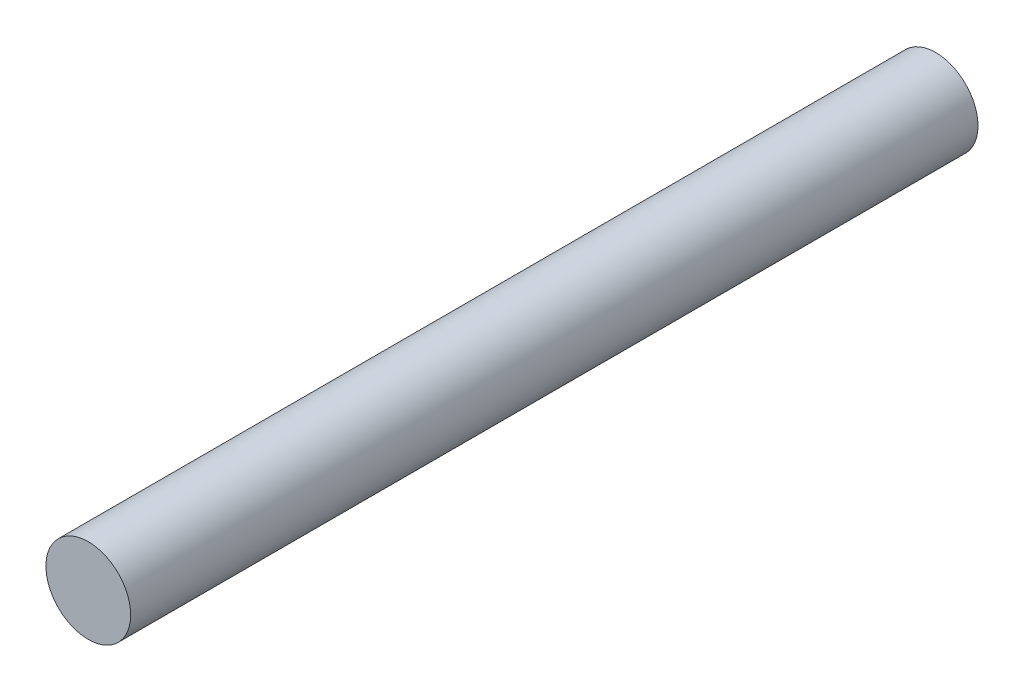
from build123d import *

# Parameters (mm, degrees)
SKETCH1_R           = 7.62
BOSS_EXTRUDE1_DEPTH = 152.4


with BuildPart() as part:
    # Sketch1 → Boss-Extrude1 (new body)
    with BuildSketch(Plane.XY):
        Circle(SKETCH1_R)
    extrude(amount=BOSS_EXTRUDE1_DEPTH)


solid = part.part
